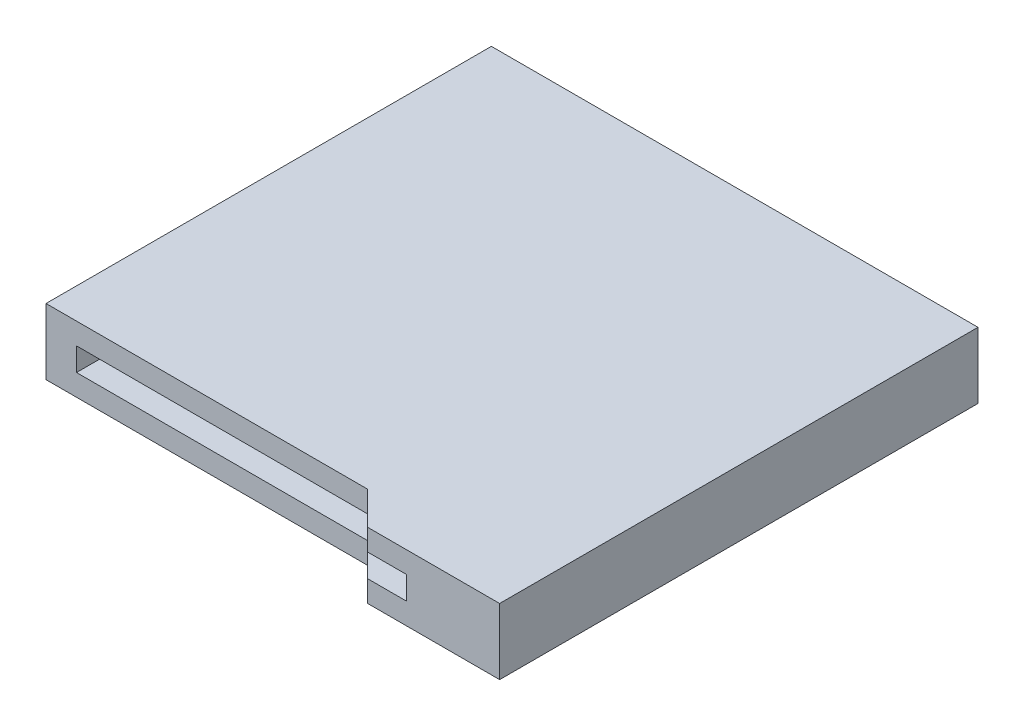
from build123d import *

# Parameters (mm, degrees)
SKETCH1_W           = 14.75
SKETCH1_H           = 14.5
BOSS_EXTRUDE1_DEPTH = 2
CUT_EXTRUDE1_DEPTH  = 2
SKETCH3_W           = 11
SKETCH3_H           = 0.7
CUT_EXTRUDE2_DEPTH  = 12
SKETCH4_R           = 0.4
BOSS_EXTRUDE2_DEPTH = 0.65


with BuildPart() as part:
    # Sketch1 → Boss-Extrude1 (new body)
    with BuildSketch(Plane(origin=(0, 0, 0), x_dir=(1, 0, 0), z_dir=(0, 1, 0))):
        Rectangle(SKETCH1_W, SKETCH1_H)
    extrude(amount=BOSS_EXTRUDE1_DEPTH)

    # Sketch2 → Cut-Extrude1 (cut)
    with BuildSketch(Plane(origin=(0, 2, 0), x_dir=(1, 0, 0), z_dir=(0, 1, 0))):
        Polygon((-7.375, -6.25), (2.375, -6.25), (3.375, -7.25), (-7.375, -7.25), align=None)
    extrude(amount=-CUT_EXTRUDE1_DEPTH, mode=Mode.SUBTRACT)

    # Sketch3 → Cut-Extrude2 (cut)
    with BuildSketch(Plane.XY.offset(7.25)):
        with Locations((-0.95, 1)):
            Rectangle(SKETCH3_W, SKETCH3_H)
    extrude(amount=-CUT_EXTRUDE2_DEPTH, mode=Mode.SUBTRACT)

    # Sketch4 → Boss-Extrude2 (add)
    with BuildSketch(Plane.XZ):
        with Locations((-4.95, 3.25)):
            Circle(SKETCH4_R)
        with Locations((3.05, 3.25)):
            Circle(SKETCH4_R)
    extrude(amount=BOSS_EXTRUDE2_DEPTH)


solid = part.part
